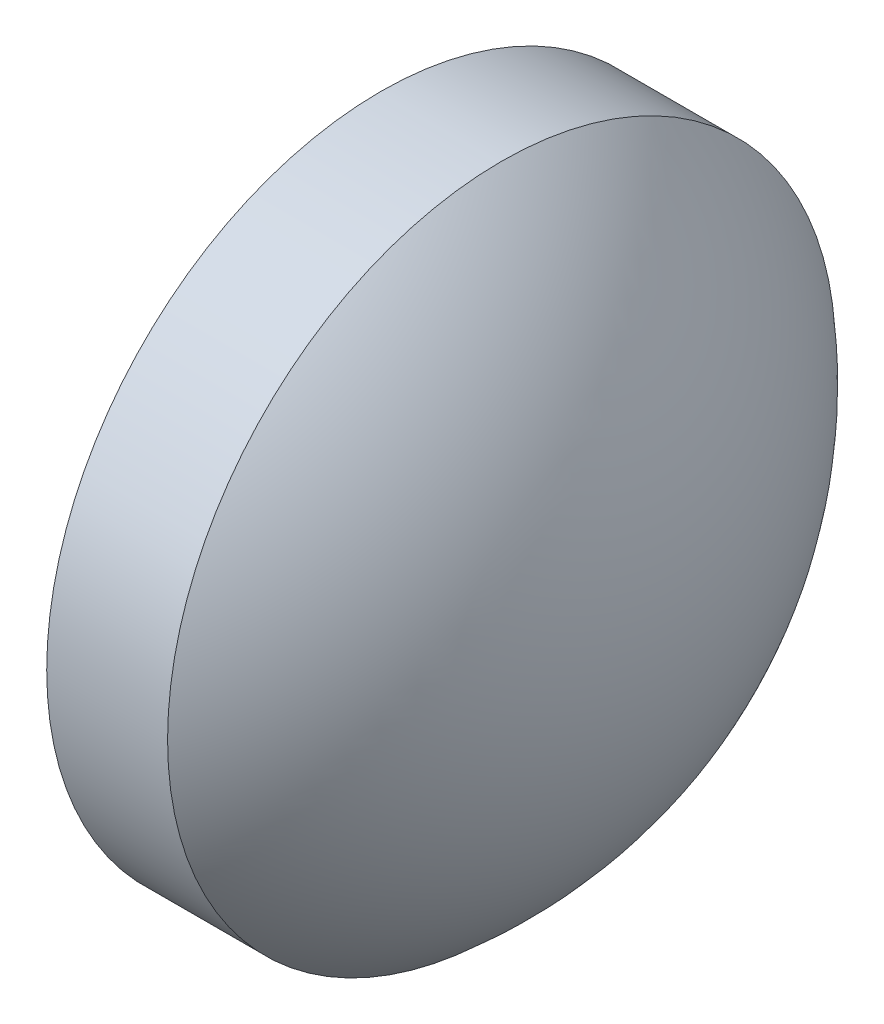
from build123d import *


with BuildPart() as part:
    # 草图1 → 旋转1 (revolve)
    with BuildSketch(Plane.XY):
        with BuildLine():
            Line((430.329696303, 112.918675999), (430.329696303, 116.068675999))
            Line((430.329696303, 116.068675999), (431.469696303, 116.068675999))
            ThreePointArc((431.469696303, 116.068675999), (432.546953054, 114.654626747), (432.929696303, 112.918675999))
            Line((432.929696303, 112.918675999), (430.329696303, 112.918675999))
        make_face()
    revolve(axis=Axis((429.468068134, 112.918675999, 0), (1, 0, 0)))


solid = part.part
